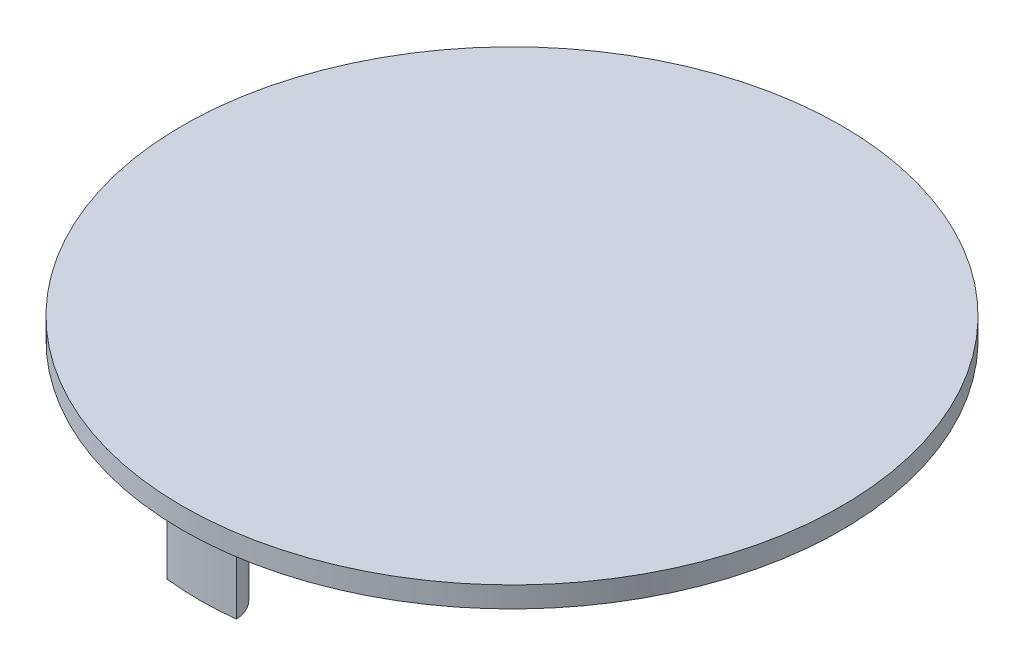
from build123d import *

# Parameters (mm, degrees)
SKETCH2_R           = 47.5
BOSS_EXTRUDE1_DEPTH = 3
BOSS_EXTRUDE2_DEPTH = 10


with BuildPart() as part:
    # Sketch2 → Boss-Extrude1 (new body)
    with BuildSketch(Plane(origin=(0, 0, 0), x_dir=(1, 0, 0), z_dir=(0, 1, 0))):
        Circle(SKETCH2_R)
    extrude(amount=BOSS_EXTRUDE1_DEPTH)

    # Sketch4 → Boss-Extrude2 (add)
    with BuildSketch(Plane.XZ):
        with BuildLine():
            ThreePointArc((4.992277988, 44.722222222), (0, 45), (-4.992277988, 44.722222222))
            ThreePointArc((-4.992277988, 44.722222222), (0, 40), (4.992277988, 44.722222222))
        make_face()
    extrude(amount=BOSS_EXTRUDE2_DEPTH)


solid = part.part
